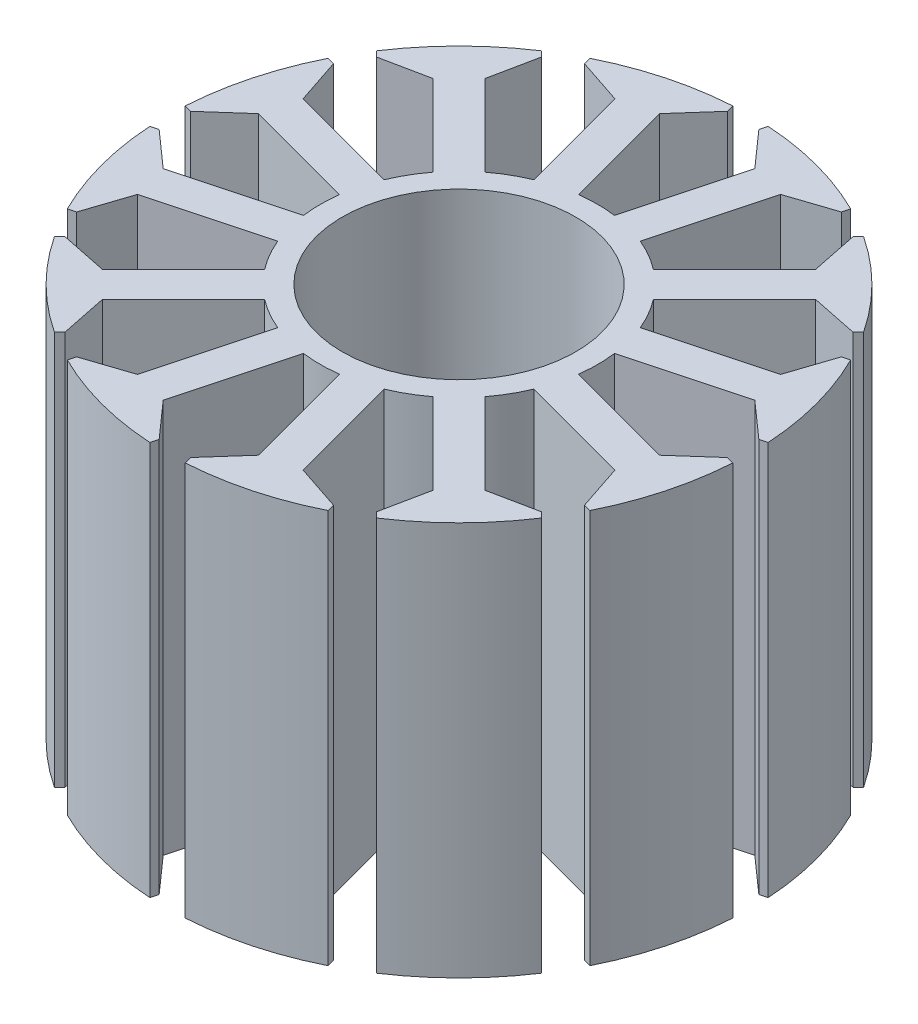
from build123d import *

# Parameters (mm, degrees)
BOSS_EXTRUDE1_DEPTH = 27


with BuildPart() as part:
    # Sketch1 → Boss-Extrude1 (new body)
    with BuildSketch(Plane(origin=(0, 0, 0), x_dir=(1, 0, 0), z_dir=(0, 1, 0))):
        with BuildLine():
            Line((1.229996254, 9.420037644), (3.261041046, 17))
            Line((3.261041046, 17), (1.075459685, 19.463398226))
            Line((1.075459685, 19.463398226), (1.209434281, 19.963398226))
            ThreePointArc((1.209434281, 19.963398226), (5.176380902, 19.318516526), (8.934298302, 17.89352715))
            Line((8.934298302, 17.89352715), (8.800323705, 17.39352715))
            Line((8.800323705, 17.39352715), (5.675855612, 16.352952387))
            Line((5.675855612, 16.352952387), (3.64481082, 8.772990031))
            ThreePointArc((3.64481082, 8.772990031), (4.206265872, 8.5180589), (4.75, 8.227241336))
            ThreePointArc((4.75, 8.227241336), (5.273722462, 7.90176255), (5.775226824, 7.542993777))
            Line((5.775226824, 7.542993777), (11.324144388, 13.091911341))
            Line((11.324144388, 13.091911341), (10.66307452, 16.318067465))
            Line((10.66307452, 16.318067465), (11.029099924, 16.684092869))
            ThreePointArc((11.029099924, 16.684092869), (14.142135624, 14.142135624), (16.684092869, 11.029099924))
            Line((16.684092869, 11.029099924), (16.318067465, 10.66307452))
            Line((16.318067465, 10.66307452), (13.091911341, 11.324144388))
            Line((13.091911341, 11.324144388), (7.542993777, 5.775226824))
            ThreePointArc((7.542993777, 5.775226824), (7.90176255, 5.273722462), (8.227241336, 4.75))
            ThreePointArc((8.227241336, 4.75), (8.5180589, 4.206265872), (8.772990031, 3.64481082))
            Line((8.772990031, 3.64481082), (16.352952387, 5.675855612))
            Line((16.352952387, 5.675855612), (17.39352715, 8.800323705))
            Line((17.39352715, 8.800323705), (17.89352715, 8.934298302))
            ThreePointArc((17.89352715, 8.934298302), (19.318516526, 5.176380902), (19.963398226, 1.209434281))
            Line((19.963398226, 1.209434281), (19.463398226, 1.075459685))
            Line((19.463398226, 1.075459685), (17, 3.261041046))
            Line((17, 3.261041046), (9.420037644, 1.229996254))
            ThreePointArc((9.420037644, 1.229996254), (9.479988334, 0.61629635), (9.5, 0))
            ThreePointArc((9.5, 0), (9.479988334, -0.61629635), (9.420037644, -1.229996254))
            Line((9.420037644, -1.229996254), (17, -3.261041046))
            Line((17, -3.261041046), (19.463398226, -1.075459685))
            Line((19.463398226, -1.075459685), (19.963398226, -1.209434281))
            ThreePointArc((19.963398226, -1.209434281), (19.318516526, -5.176380902), (17.89352715, -8.934298302))
            Line((17.89352715, -8.934298302), (17.39352715, -8.800323705))
            Line((17.39352715, -8.800323705), (16.352952387, -5.675855612))
            Line((16.352952387, -5.675855612), (8.772990031, -3.64481082))
            ThreePointArc((8.772990031, -3.64481082), (8.5180589, -4.206265872), (8.227241336, -4.75))
            ThreePointArc((8.227241336, -4.75), (7.90176255, -5.273722462), (7.542993777, -5.775226824))
            Line((7.542993777, -5.775226824), (13.091911341, -11.324144388))
            Line((13.091911341, -11.324144388), (16.318067465, -10.66307452))
            Line((16.318067465, -10.66307452), (16.684092869, -11.029099924))
            ThreePointArc((16.684092869, -11.029099924), (14.142135624, -14.142135624), (11.029099924, -16.684092869))
            Line((11.029099924, -16.684092869), (10.66307452, -16.318067465))
            Line((10.66307452, -16.318067465), (11.324144388, -13.091911341))
            Line((11.324144388, -13.091911341), (5.775226824, -7.542993777))
            ThreePointArc((5.775226824, -7.542993777), (5.273722462, -7.90176255), (4.75, -8.227241336))
            ThreePointArc((4.75, -8.227241336), (4.206265872, -8.5180589), (3.64481082, -8.772990031))
            Line((3.64481082, -8.772990031), (5.675855612, -16.352952387))
            Line((5.675855612, -16.352952387), (8.800323705, -17.39352715))
            Line((8.800323705, -17.39352715), (8.934298302, -17.89352715))
            ThreePointArc((8.934298302, -17.89352715), (5.176380902, -19.318516526), (1.209434281, -19.963398226))
            Line((1.209434281, -19.963398226), (1.075459685, -19.463398226))
            Line((1.075459685, -19.463398226), (3.261041046, -17))
            Line((3.261041046, -17), (1.229996254, -9.420037644))
            ThreePointArc((1.229996254, -9.420037644), (0.61629635, -9.479988334), (0, -9.5))
            ThreePointArc((0, -9.5), (-0.61629635, -9.479988334), (-1.229996254, -9.420037644))
            Line((-1.229996254, -9.420037644), (-3.261041046, -17))
            Line((-3.261041046, -17), (-1.075459685, -19.463398226))
            Line((-1.075459685, -19.463398226), (-1.209434281, -19.963398226))
            ThreePointArc((-1.209434281, -19.963398226), (-5.176380902, -19.318516526), (-8.934298302, -17.89352715))
            Line((-8.934298302, -17.89352715), (-8.800323705, -17.39352715))
            Line((-8.800323705, -17.39352715), (-5.675855612, -16.352952387))
            Line((-5.675855612, -16.352952387), (-3.64481082, -8.772990031))
            ThreePointArc((-3.64481082, -8.772990031), (-4.206265872, -8.5180589), (-4.75, -8.227241336))
            ThreePointArc((-4.75, -8.227241336), (-5.273722462, -7.90176255), (-5.775226824, -7.542993777))
            Line((-5.775226824, -7.542993777), (-11.324144388, -13.091911341))
            Line((-11.324144388, -13.091911341), (-10.66307452, -16.318067465))
            Line((-10.66307452, -16.318067465), (-11.029099924, -16.684092869))
            ThreePointArc((-11.029099924, -16.684092869), (-14.142135624, -14.142135624), (-16.684092869, -11.029099924))
            Line((-16.684092869, -11.029099924), (-16.318067465, -10.66307452))
            Line((-16.318067465, -10.66307452), (-13.091911341, -11.324144388))
            Line((-13.091911341, -11.324144388), (-7.542993777, -5.775226824))
            ThreePointArc((-7.542993777, -5.775226824), (-7.90176255, -5.273722462), (-8.227241336, -4.75))
            ThreePointArc((-8.227241336, -4.75), (-8.5180589, -4.206265872), (-8.772990031, -3.64481082))
            Line((-8.772990031, -3.64481082), (-16.352952387, -5.675855612))
            Line((-16.352952387, -5.675855612), (-17.39352715, -8.800323705))
            Line((-17.39352715, -8.800323705), (-17.89352715, -8.934298302))
            ThreePointArc((-17.89352715, -8.934298302), (-19.318516526, -5.176380902), (-19.963398226, -1.209434281))
            Line((-19.963398226, -1.209434281), (-19.463398226, -1.075459685))
            Line((-19.463398226, -1.075459685), (-17, -3.261041046))
            Line((-17, -3.261041046), (-9.420037644, -1.229996254))
            ThreePointArc((-9.420037644, -1.229996254), (-9.479988334, -0.61629635), (-9.5, 0))
            ThreePointArc((-9.5, 0), (-9.479988334, 0.61629635), (-9.420037644, 1.229996254))
            Line((-9.420037644, 1.229996254), (-17, 3.261041046))
            Line((-17, 3.261041046), (-19.463398226, 1.075459685))
            Line((-19.463398226, 1.075459685), (-19.963398226, 1.209434281))
            ThreePointArc((-19.963398226, 1.209434281), (-19.318516526, 5.176380902), (-17.89352715, 8.934298302))
            Line((-17.89352715, 8.934298302), (-17.39352715, 8.800323705))
            Line((-17.39352715, 8.800323705), (-16.352952387, 5.675855612))
            Line((-16.352952387, 5.675855612), (-8.772990031, 3.64481082))
            ThreePointArc((-8.772990031, 3.64481082), (-8.5180589, 4.206265872), (-8.227241336, 4.75))
            ThreePointArc((-8.227241336, 4.75), (-7.90176255, 5.273722462), (-7.542993777, 5.775226824))
            Line((-7.542993777, 5.775226824), (-13.091911341, 11.324144388))
            Line((-13.091911341, 11.324144388), (-16.318067465, 10.66307452))
            Line((-16.318067465, 10.66307452), (-16.684092869, 11.029099924))
            ThreePointArc((-16.684092869, 11.029099924), (-14.142135624, 14.142135624), (-11.029099924, 16.684092869))
            Line((-11.029099924, 16.684092869), (-10.66307452, 16.318067465))
            Line((-10.66307452, 16.318067465), (-11.324144388, 13.091911341))
            Line((-11.324144388, 13.091911341), (-5.775226824, 7.542993777))
            ThreePointArc((-5.775226824, 7.542993777), (-5.273722462, 7.90176255), (-4.75, 8.227241336))
            ThreePointArc((-4.75, 8.227241336), (-4.206265872, 8.5180589), (-3.64481082, 8.772990031))
            Line((-3.64481082, 8.772990031), (-5.675855612, 16.352952387))
            Line((-5.675855612, 16.352952387), (-8.800323705, 17.39352715))
            Line((-8.800323705, 17.39352715), (-8.934298302, 17.89352715))
            ThreePointArc((-8.934298302, 17.89352715), (-5.176380902, 19.318516526), (-1.209434281, 19.963398226))
            Line((-1.209434281, 19.963398226), (-1.075459685, 19.463398226))
            Line((-1.075459685, 19.463398226), (-3.261041046, 17))
            Line((-3.261041046, 17), (-1.229996254, 9.420037644))
            ThreePointArc((-1.229996254, 9.420037644), (-0.61629635, 9.479988334), (0, 9.5))
            ThreePointArc((0, 9.5), (0.61629635, 9.479988334), (1.229996254, 9.420037644))
        make_face()
        with BuildLine():
            ThreePointArc((4, 6.92820323), (2.070552361, 7.72740661), (0, 8))
            ThreePointArc((0, 8), (-2.070552361, 7.72740661), (-4, 6.92820323))
            ThreePointArc((-4, 6.92820323), (-5.656854249, 5.656854249), (-6.92820323, 4))
            ThreePointArc((-6.92820323, 4), (-7.72740661, 2.070552361), (-8, 0))
            ThreePointArc((-8, 0), (-7.72740661, -2.070552361), (-6.92820323, -4))
            ThreePointArc((-6.92820323, -4), (-5.656854249, -5.656854249), (-4, -6.92820323))
            ThreePointArc((-4, -6.92820323), (-2.070552361, -7.72740661), (0, -8))
            ThreePointArc((0, -8), (2.070552361, -7.72740661), (4, -6.92820323))
            ThreePointArc((4, -6.92820323), (5.656854249, -5.656854249), (6.92820323, -4))
            ThreePointArc((6.92820323, -4), (7.72740661, -2.070552361), (8, 0))
            ThreePointArc((8, 0), (7.72740661, 2.070552361), (6.92820323, 4))
            ThreePointArc((6.92820323, 4), (5.656854249, 5.656854249), (4, 6.92820323))
        make_face(mode=Mode.SUBTRACT)
    extrude(amount=BOSS_EXTRUDE1_DEPTH)


solid = part.part
